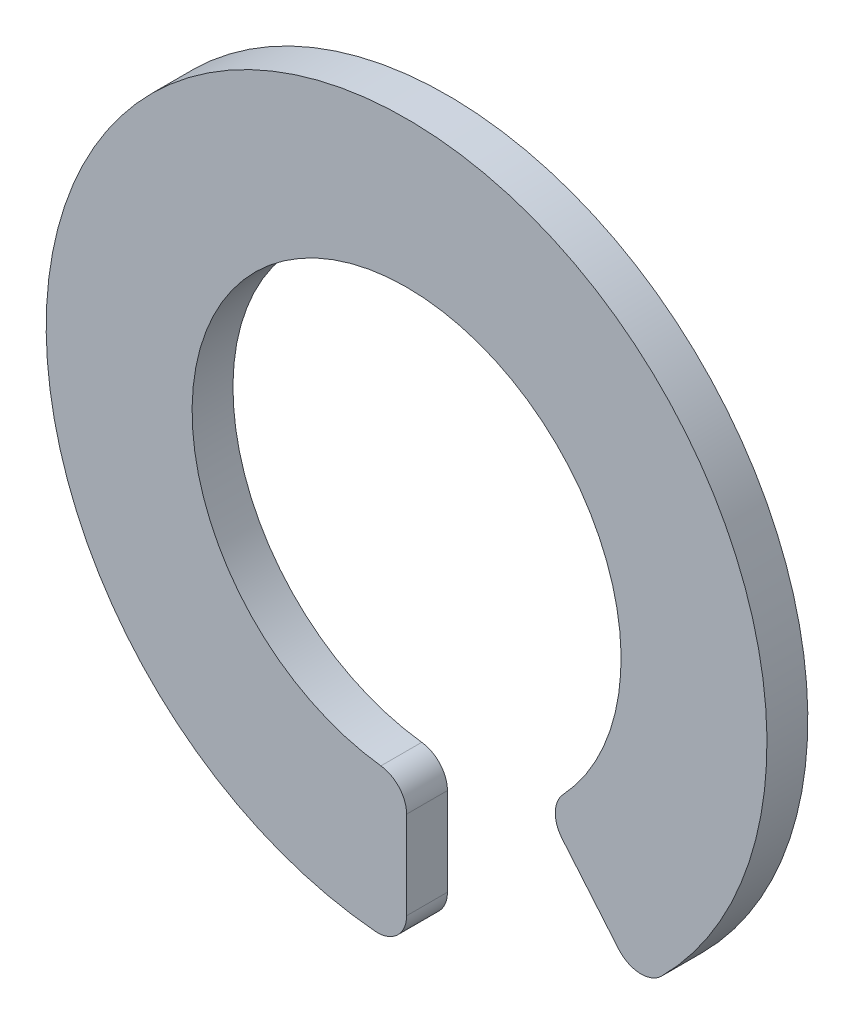
from build123d import *

# Parameters (mm, degrees)
BOSS_EXTRU_1_DEPTH = 0.28
CONG_1_R           = 0.2


with BuildPart() as part:
    # Esquisse1 → Boss.-Extru.1 (new body)
    with BuildSketch(Plane.XY):
        with BuildLine():
            Line((0, -1.47), (0, -2.47))
            ThreePointArc((0, -2.47), (-0.844789754, 2.321040773), (1.587685396, -1.892129775))
            Line((1.587685396, -1.892129775), (0.944897786, -1.126085331))
            ThreePointArc((0.944897786, -1.126085331), (-0.502769611, 1.381348153), (0, -1.47))
        make_face()
    extrude(amount=BOSS_EXTRU_1_DEPTH)

    # Congé1
    cong_1_edges = [part.edges().sort_by_distance(p)[0] for p in [
        (0, -1.47, 0.14),
        (0, -2.47, 0.14),
        (1.587685396, -1.892129775, 0.14),
        (0.944897786, -1.126085331, 0.14),
    ]]
    fillet(cong_1_edges, radius=CONG_1_R)


solid = part.part
